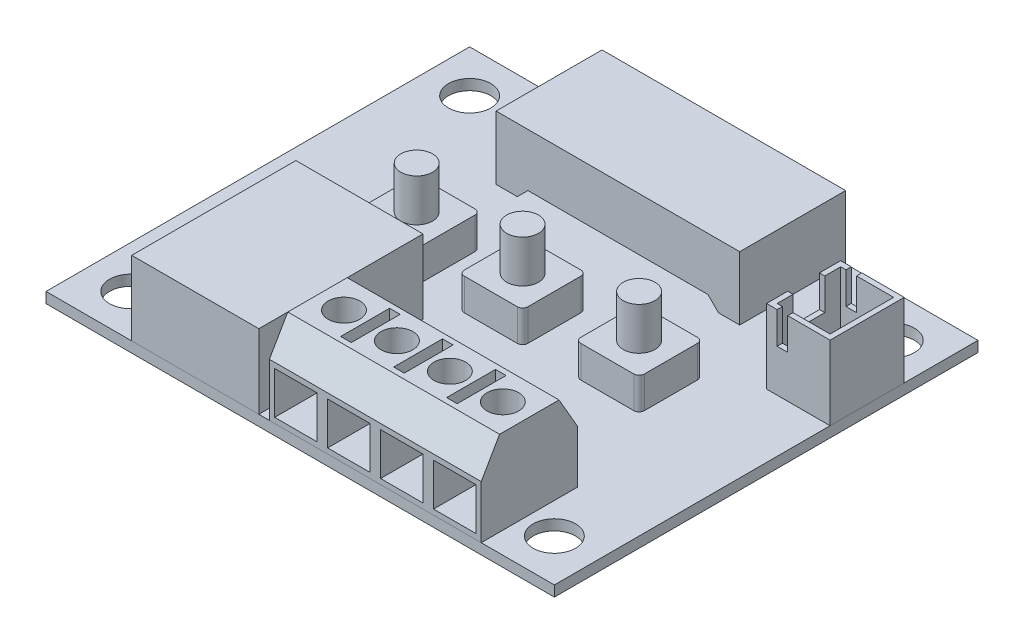
from build123d import *

# Parameters (mm, degrees)
SKETCH1_W             = 48
SKETCH1_H             = 40
BOSS_EXTRUDE1_DEPTH   = 1
SKETCH2_W             = 28
SKETCH2_H             = 20
BOSS_EXTRUDE2_DEPTH   = 2
SKETCH3_R             = 2
CUT_EXTRUDE1_DEPTH    = 4
SKETCH4_W             = 23
SKETCH4_H             = 10
BOSS_EXTRUDE3_DEPTH   = 6
SKETCH5_W             = 6
SKETCH5_H             = 7
BOSS_EXTRUDE4_DEPTH   = 7
SHELL1_T              = -0.5
SKETCH6_W             = 1
SKETCH6_H             = 0.5
SKETCH6_W_2           = 0.5
SKETCH6_H_2           = 3
CUT_EXTRUDE2_DEPTH    = 3
CUT_EXTRUDE3_DEPTH    = 11
SKETCH8_W             = 12
SKETCH8_H             = 15.5
BOSS_EXTRUDE5_DEPTH   = 7
SKETCH9_W             = 20
SKETCH9_H             = 9.077096831
BOSS_EXTRUDE6_DEPTH   = 8
CHAMFER1_SIZE         = 3
CHAMFER1_SIZE2        = 1.732050808
CHAMFER1_PART_2_SIZE  = 3
CHAMFER1_PART_2_SIZE2 = 1.732050808
SKETCH10_W            = 4
SKETCH10_H            = 4
CUT_EXTRUDE4_DEPTH    = 5
SKETCH11_R            = 1.5
SKETCH11_W            = 1
SKETCH11_H            = 4.612995216
CUT_EXTRUDE5_DEPTH    = 3
BOSS_EXTRUDE7_DEPTH   = 3
BOSS_EXTRUDE7_2_DEPTH = 3
BOSS_EXTRUDE7_3_DEPTH = 3
SKETCH13_R            = 1.5
BOSS_EXTRUDE8_DEPTH   = 4


with BuildPart() as part:
    # Sketch1 → Boss-Extrude1 (new body)
    with BuildSketch(Plane(origin=(0, 0, 0), x_dir=(1, 0, 0), z_dir=(0, 1, 0))):
        Rectangle(SKETCH1_W, SKETCH1_H)
    extrude(amount=BOSS_EXTRUDE1_DEPTH)

    # Sketch2 → Boss-Extrude2 (add)
    with BuildSketch(Plane.XZ):
        Rectangle(SKETCH2_W, SKETCH2_H)
    extrude(amount=BOSS_EXTRUDE2_DEPTH)

    # Sketch3 → Cut-Extrude1 (cut, through all)
    with BuildSketch(Plane(origin=(0, 1, 0), x_dir=(1, 0, 0), z_dir=(0, 1, 0))):
        with Locations((-20, -16)):
            Circle(SKETCH3_R)
        with Locations((20, -16)):
            Circle(SKETCH3_R)
        with Locations((20, 16)):
            Circle(SKETCH3_R)
        with Locations((-20, 16)):
            Circle(SKETCH3_R)
    extrude(amount=-CUT_EXTRUDE1_DEPTH, mode=Mode.SUBTRACT)


with BuildPart() as body_2:
    # Sketch4 → Boss-Extrude3 (new body)
    with BuildSketch(Plane(origin=(0, 1, 0), x_dir=(1, 0, 0), z_dir=(0, 1, 0))):
        with Locations((0, 15)):
            Rectangle(SKETCH4_W, SKETCH4_H)
    extrude(amount=BOSS_EXTRUDE3_DEPTH)

    # Sketch7 → Cut-Extrude3 (cut, through all)
    with BuildSketch(Plane.XY.offset(-10)):
        Polygon((-9.5, 1), (9.5, 1), (8.5, 2), (-8.5, 2), align=None)
    extrude(amount=-CUT_EXTRUDE3_DEPTH, mode=Mode.SUBTRACT)


with BuildPart() as body_3:
    # Sketch5 → Boss-Extrude4 (new body)
    with BuildSketch(Plane(origin=(0, 1, 0), x_dir=(1, 0, 0), z_dir=(0, 1, 0))):
        with Locations((21, 9.533602838)):
            Rectangle(SKETCH5_W, SKETCH5_H)
    extrude(amount=BOSS_EXTRUDE4_DEPTH)

    # Shell1
    shell1_openings = [body_3.faces().sort_by_distance(p)[0] for p in [
        (21, 8, -9.533602838),
    ]]
    offset(amount=SHELL1_T, openings=shell1_openings, kind=Kind.INTERSECTION)

    # Sketch6 → Cut-Extrude2 (cut)
    with BuildSketch(Plane(origin=(0, 8, 0), x_dir=(1, 0, 0), z_dir=(0, 1, 0))):
        with Locations((19.5, 12.783602838)):
            Rectangle(SKETCH6_W, SKETCH6_H)
        with Locations((18.25, 9.533602838)):
            Rectangle(SKETCH6_W_2, SKETCH6_H_2)
        with Locations((19.5, 6.283602838)):
            Rectangle(SKETCH6_W, SKETCH6_H)
    extrude(amount=-CUT_EXTRUDE2_DEPTH, mode=Mode.SUBTRACT)


with BuildPart() as body_4:
    # Sketch8 → Boss-Extrude5 (new body, through all)
    with BuildSketch(Plane(origin=(0, 1, 0), x_dir=(1, 0, 0), z_dir=(0, 1, 0))):
        with Locations((-9.905413633, -12.25)):
            Rectangle(SKETCH8_W, SKETCH8_H)
    extrude(amount=BOSS_EXTRUDE5_DEPTH)


with BuildPart() as body_5:
    # Sketch9 → Boss-Extrude6 (new body)
    with BuildSketch(Plane(origin=(0, 1, 0), x_dir=(1, 0, 0), z_dir=(0, 1, 0))):
        with Locations((7.094586367, -15.461451585)):
            Rectangle(SKETCH9_W, SKETCH9_H)
    extrude(amount=BOSS_EXTRUDE6_DEPTH)

    # Chamfer1
    chamfer1_edges = [body_5.edges().sort_by_distance(p)[0] for p in [
        (7.094586367, 9, 10.922903169),
    ]]
    chamfer1_side = [body_5.faces().sort_by_distance(p)[0] for p in [
        (7.094586367, 5, 10.922903169),
    ]]
    chamfer(chamfer1_edges, length=CHAMFER1_SIZE, length2=CHAMFER1_SIZE2, reference=chamfer1_side[0])

    # Chamfer1 part 2
    chamfer1_part_2_edges = [body_5.edges().sort_by_distance(p)[0] for p in [
        (7.094586367, 9, 20),
    ]]
    chamfer1_part_2_side = [body_5.faces().sort_by_distance(p)[0] for p in [
        (7.094586367, 5, 20),
    ]]
    chamfer(chamfer1_part_2_edges, length=CHAMFER1_PART_2_SIZE, length2=CHAMFER1_PART_2_SIZE2, reference=chamfer1_part_2_side[0])

    # Sketch10 → Cut-Extrude4 (cut)
    with BuildSketch(Plane.XY.offset(20)):
        with Locations((14.594586367, 3.5)):
            Rectangle(SKETCH10_W, SKETCH10_H)
        with Locations((9.594586367, 3.5)):
            Rectangle(SKETCH10_W, SKETCH10_H)
        with Locations((4.594586367, 3.5)):
            Rectangle(SKETCH10_W, SKETCH10_H)
        with Locations((-0.405413633, 3.5)):
            Rectangle(SKETCH10_W, SKETCH10_H)
    extrude(amount=-CUT_EXTRUDE4_DEPTH, mode=Mode.SUBTRACT)

    # Sketch11 → Cut-Extrude5 (cut)
    with BuildSketch(Plane(origin=(0, 9, 0), x_dir=(1, 0, 0), z_dir=(0, 1, 0))):
        with Locations((14.594586367, -15.461451584)):
            Circle(SKETCH11_R)
        with Locations((9.594586367, -15.461451584)):
            Circle(SKETCH11_R)
        with Locations((4.594586367, -15.461451584)):
            Circle(SKETCH11_R)
        with Locations((-0.405413633, -15.461451584)):
            Circle(SKETCH11_R)
        with Locations((12.094586367, -15.461451584)):
            Rectangle(SKETCH11_W, SKETCH11_H)
        with Locations((7.094586367, -15.461451584)):
            Rectangle(SKETCH11_W, SKETCH11_H)
        with Locations((2.094586367, -15.461451584)):
            Rectangle(SKETCH11_W, SKETCH11_H)
    extrude(amount=-CUT_EXTRUDE5_DEPTH, mode=Mode.SUBTRACT)


with BuildPart() as body_6:
    # Sketch12 → Boss-Extrude7 (new body)
    with BuildSketch(Plane(origin=(0, 1, 0), x_dir=(1, 0, 0), z_dir=(0, 1, 0))):
        with BuildLine():
            Line((-2.5, 4), (2.5, 4))
            ThreePointArc((2.5, 4), (2.853553391, 3.853553391), (3, 3.5))
            Line((3, 3.5), (3, -1.5))
            ThreePointArc((3, -1.5), (2.853553391, -1.853553391), (2.5, -2))
            Line((2.5, -2), (-2.5, -2))
            ThreePointArc((-2.5, -2), (-2.853553391, -1.853553391), (-3, -1.5))
            Line((-3, -1.5), (-3, 3.5))
            ThreePointArc((-3, 3.5), (-2.853553391, 3.853553391), (-2.5, 4))
        make_face()
    extrude(amount=BOSS_EXTRUDE7_DEPTH)



with BuildPart() as body_7:
    # Sketch12 → Boss-Extrude7 2 (new body)
    with BuildSketch(Plane(origin=(0, 1, 0), x_dir=(1, 0, 0), z_dir=(0, 1, 0))):
        with BuildLine():
            Line((-13, 3.5), (-13, -1.5))
            ThreePointArc((-13, -1.5), (-12.853553391, -1.853553391), (-12.5, -2))
            Line((-12.5, -2), (-7.5, -2))
            ThreePointArc((-7.5, -2), (-7.146446609, -1.853553391), (-7, -1.5))
            Line((-7, -1.5), (-7, 3.5))
            ThreePointArc((-7, 3.5), (-7.146446609, 3.853553391), (-7.5, 4))
            Line((-7.5, 4), (-12.5, 4))
            ThreePointArc((-12.5, 4), (-12.853553391, 3.853553391), (-13, 3.5))
        make_face()
    extrude(amount=BOSS_EXTRUDE7_2_DEPTH)


with BuildPart() as body_8:
    # Sketch12 → Boss-Extrude7 3 (new body)
    with BuildSketch(Plane(origin=(0, 1, 0), x_dir=(1, 0, 0), z_dir=(0, 1, 0))):
        with BuildLine():
            Line((8, 3.5), (8, -1.5))
            ThreePointArc((8, -1.5), (8.146446609, -1.853553391), (8.5, -2))
            Line((8.5, -2), (13.5, -2))
            ThreePointArc((13.5, -2), (13.853553391, -1.853553391), (14, -1.5))
            Line((14, -1.5), (14, 3.5))
            ThreePointArc((14, 3.5), (13.853553391, 3.853553391), (13.5, 4))
            Line((13.5, 4), (8.5, 4))
            ThreePointArc((8.5, 4), (8.146446609, 3.853553391), (8, 3.5))
        make_face()
    extrude(amount=BOSS_EXTRUDE7_3_DEPTH)


with BuildPart() as body_6_1:
    add(body_6.part)

    add(body_7.part)  # Boss-Extrude8 merges body 7

    add(body_8.part)  # Boss-Extrude8 merges body 8
    # Sketch13 → Boss-Extrude8 (add)
    with BuildSketch(Plane(origin=(0, 4, 0), x_dir=(1, 0, 0), z_dir=(0, 1, 0))):
        with Locations((0, 1)):
            Circle(SKETCH13_R)
        with Locations((11, 1)):
            Circle(SKETCH13_R)
        with Locations((-10, 1)):
            Circle(SKETCH13_R)
    extrude(amount=BOSS_EXTRUDE8_DEPTH)


solid = Compound([part.part, body_2.part, body_3.part, body_4.part, body_5.part, body_6_1.part])
